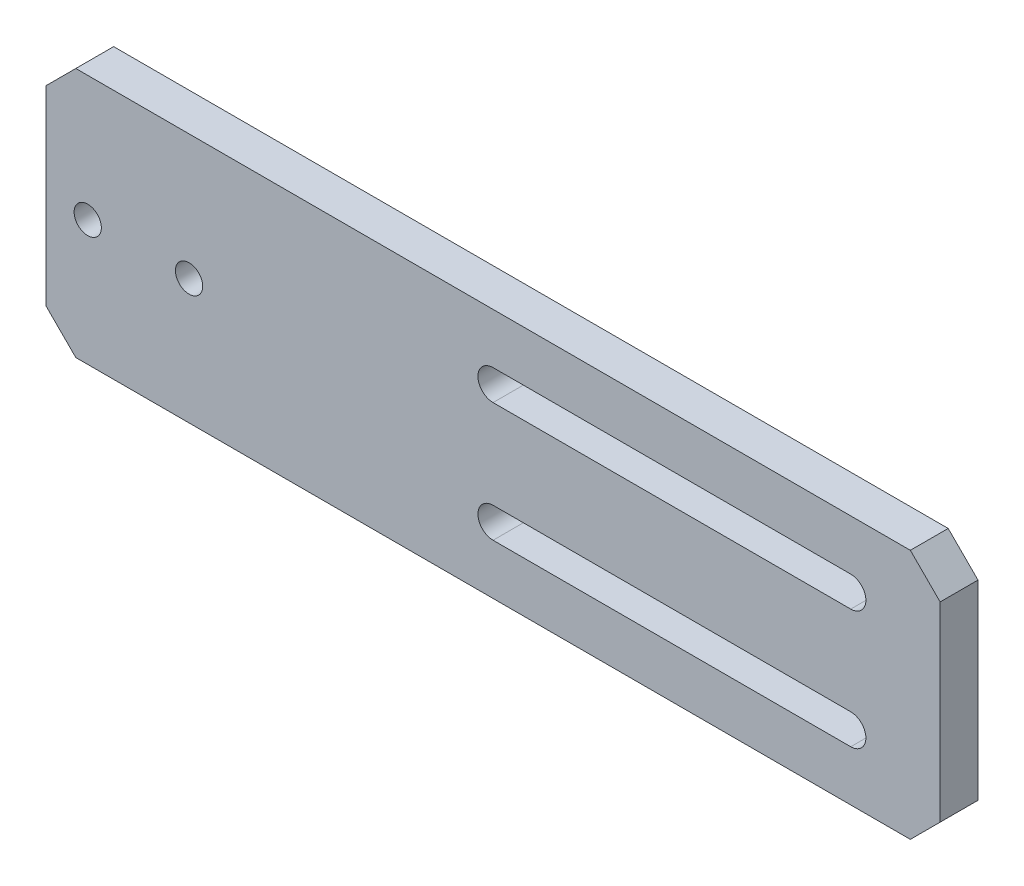
from build123d import *

# Parameters (mm, degrees)
SKETCH1_W           = 200
SKETCH1_H           = 42
BOSS_EXTRUDE1_DEPTH = 6.35
SKETCH4_R           = 2.286
CUT_EXTRUDE3_DEPTH  = 7.35
CHAMFER1_SIZE       = 5
SKETCH9_R           = 2.286
CUT_EXTRUDE8_DEPTH  = 7.35
SKETCH12_R          = 2.286
CUT_EXTRUDE11_DEPTH = 7.35
SKETCH13_R          = 2.286
CUT_EXTRUDE12_DEPTH = 10


with BuildPart() as part:
    # Sketch1 → Boss-Extrude1 (new body)
    with BuildSketch(Plane.XY):
        Rectangle(SKETCH1_W, SKETCH1_H)
    extrude(amount=BOSS_EXTRUDE1_DEPTH)

    # Sketch4 → Cut-Extrude3 (cut, through all)
    with BuildSketch(Plane.XY.offset(6.35)):
        with Locations((-76, 0)):
            Circle(SKETCH4_R)
    extrude(amount=-CUT_EXTRUDE3_DEPTH, mode=Mode.SUBTRACT)

    # Chamfer1
    chamfer1_edges = [part.edges().sort_by_distance(p)[0] for p in [
        (100, -21, 3.175),
        (-100, -21, 3.175),
        (-100, 21, 3.175),
        (100, 21, 3.175),
    ]]
    chamfer(chamfer1_edges, length=CHAMFER1_SIZE)

    # Sketch9 → Cut-Extrude8 (cut, through all)
    with BuildSketch(Plane.XY.offset(6.35)):
        with Locations((80, 0)):
            Circle(SKETCH9_R)
    extrude(amount=-CUT_EXTRUDE8_DEPTH, mode=Mode.SUBTRACT)

    # Sketch12 → Cut-Extrude11 (cut, through all)
    with BuildSketch(Plane.XY.offset(6.35)):
        with Locations((-93, 0)):
            Circle(SKETCH12_R)
    extrude(amount=-CUT_EXTRUDE11_DEPTH, mode=Mode.SUBTRACT)

    # Sketch13 → Cut-Extrude12 (cut)
    with BuildSketch(Plane.XY.offset(6.35)):
        Polygon((45, 21), (50, 16), (50, -16), (45, -21), (95, -21), (100, -16), (100, 16), (95, 21), align=None)
        with Locations((80, 0)):
            Circle(SKETCH13_R, mode=Mode.SUBTRACT)
        with BuildLine():
            ThreePointArc((35, -7.46), (37.54, -10), (35, -12.54))
            Line((35, -12.54), (-25, -12.54))
            ThreePointArc((-25, -12.54), (-27.54, -10), (-25, -7.46))
            Line((-25, -7.46), (35, -7.46))
        make_face()
        with BuildLine():
            Line((-25, 7.46), (35, 7.46))
            ThreePointArc((35, 7.46), (37.54, 10), (35, 12.54))
            Line((35, 12.54), (-25, 12.54))
            ThreePointArc((-25, 12.54), (-27.54, 10), (-25, 7.46))
        make_face()
    extrude(amount=-CUT_EXTRUDE12_DEPTH, mode=Mode.SUBTRACT)


solid = part.part
